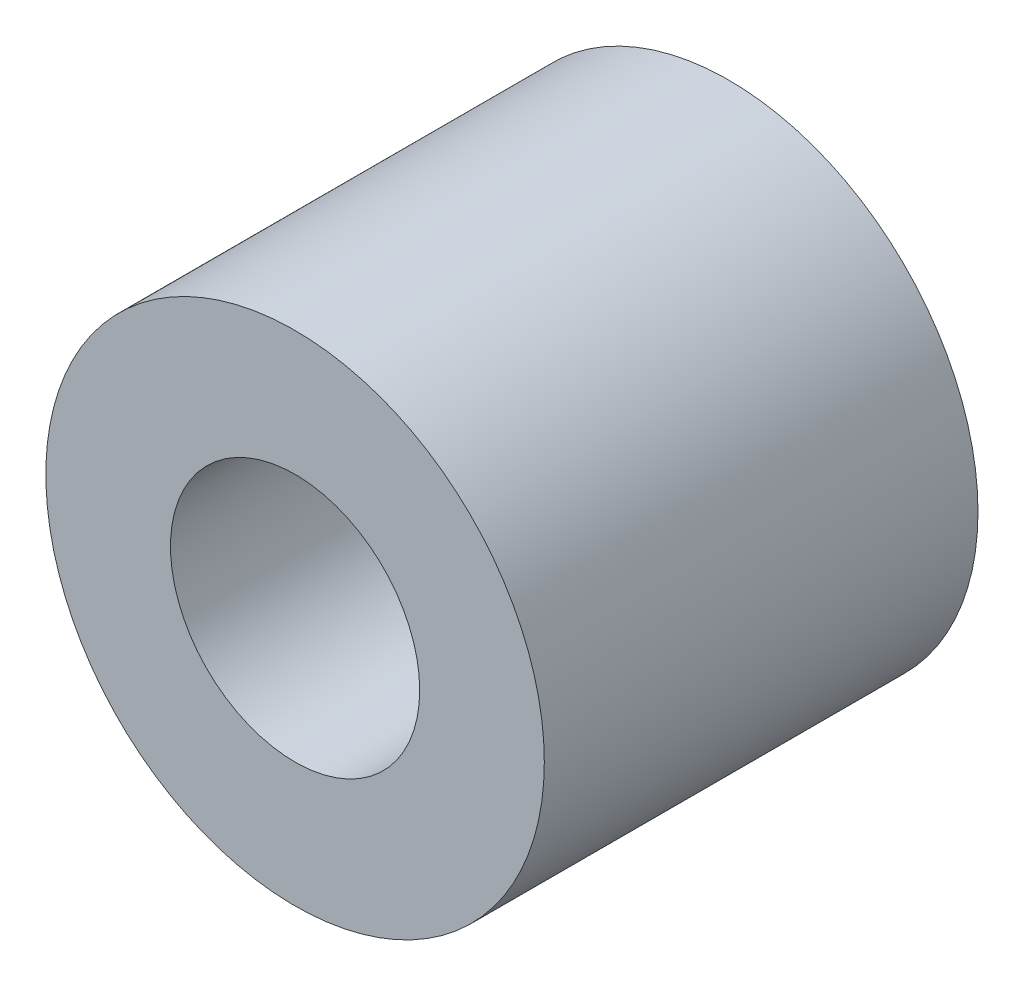
from build123d import *

# Parameters (mm, degrees)
SKETCH1_R                 = 5
BOSS_EXTRUDE1_DEPTH       = 8.7
F_5_0MM_DOWEL_HOLE1_D     = 5
F_5_0MM_DOWEL_HOLE1_DEPTH = 8.7


with BuildPart() as part:
    # Sketch1 → Boss-Extrude1 (new body)
    with BuildSketch(Plane.XY):
        Circle(SKETCH1_R)
    extrude(amount=BOSS_EXTRUDE1_DEPTH)

    # Ø5.0mm Dowel Hole1
    with Locations(Plane.XY.offset(8.7)):
        with Locations((0, 0)):
            Hole(F_5_0MM_DOWEL_HOLE1_D / 2, depth=F_5_0MM_DOWEL_HOLE1_DEPTH)


solid = part.part
